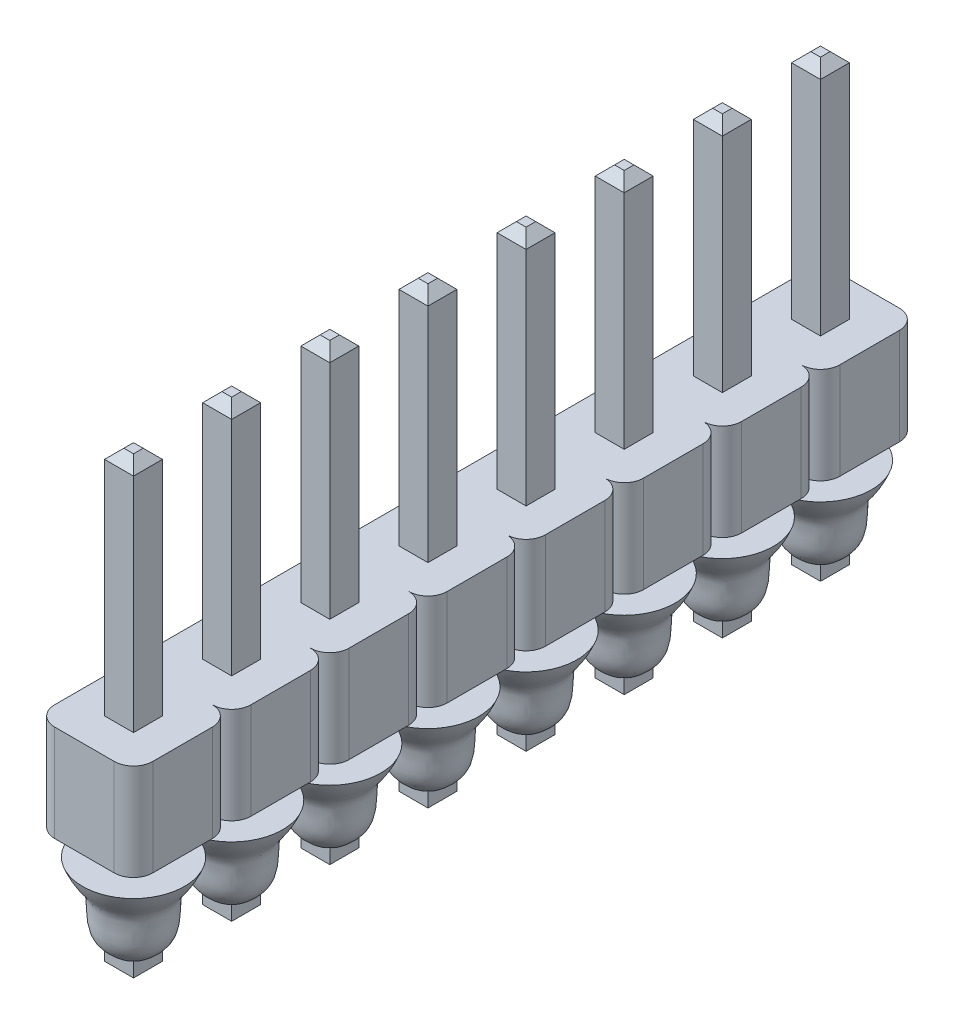
from build123d import *

# Parameters (mm, degrees)
BOSS_EXTRUDE1_DEPTH        = 2.5
LPATTERN1_COUNT            = 8
LPATTERN1_PITCH            = 2.54
BOSS_EXTRUDE2_START        = -3.25
SKETCH2_W                  = 0.75
SKETCH2_H                  = 0.75
BOSS_EXTRUDE2_DEPTH        = 11.75
CHAMFER1_SIZE              = 0.25
LPATTERN2_COUNT            = 8
LPATTERN2_PITCH            = 2.54
CHAMFER1_OF_LPATTERN2_SIZE = 0.25
PADR_O_LINEAR1_COUNT       = 8
PADR_O_LINEAR1_PITCH       = 2.54


with BuildPart() as part:
    # Sketch1 → Boss-Extrude1 (new body)
    with BuildSketch(Plane(origin=(0, 0, 0), x_dir=(-1, 0, 0), z_dir=(0, 1, 0))):
        with BuildLine():
            Line((-0.77, 1.27), (0.77, 1.27))
            ThreePointArc((0.77, 1.27), (1.123553391, 1.123553391), (1.27, 0.77))
            Line((1.27, 0.77), (1.27, -0.77))
            ThreePointArc((1.27, -0.77), (1.123553391, -1.123553391), (0.77, -1.27))
            Line((0.77, -1.27), (-0.77, -1.27))
            ThreePointArc((-0.77, -1.27), (-1.123553391, -1.123553391), (-1.27, -0.77))
            Line((-1.27, -0.77), (-1.27, 0.77))
            ThreePointArc((-1.27, 0.77), (-1.123553391, 1.123553391), (-0.77, 1.27))
        make_face()
    boss_extrude1 = extrude(amount=BOSS_EXTRUDE1_DEPTH)

    # LPattern1: Boss-Extrude1 ×8
    with Locations(*[(0, 0, i * LPATTERN1_PITCH) for i in range(1, LPATTERN1_COUNT)]):
        add(boss_extrude1)

    # Sketch2 → Boss-Extrude2 (add)
    with BuildSketch(Plane(origin=(0, 0, 0), x_dir=(-1, 0, 0), z_dir=(0, 1, 0)).offset(BOSS_EXTRUDE2_START)):
        Rectangle(SKETCH2_W, SKETCH2_H)
    boss_extrude2 = extrude(amount=BOSS_EXTRUDE2_DEPTH)

    # Chamfer1
    chamfer1_edges = [part.edges().sort_by_distance(p)[0] for p in [
        (0, -3.25, 0.375),
        (-0.375, -3.25, 0),
        (0.375, -3.25, 0),
        (0, -3.25, -0.375),
        (0, 8.5, 0.375),
        (-0.375, 8.5, 0),
        (0, 8.5, -0.375),
        (0.375, 8.5, 0),
    ]]
    chamfer(chamfer1_edges, length=CHAMFER1_SIZE)

    # LPattern2: Boss-Extrude2 ×8
    with Locations(*[(0, 0, i * LPATTERN2_PITCH) for i in range(1, LPATTERN2_COUNT)]):
        add(boss_extrude2)

    # Chamfer1 of LPattern2
    chamfer1_of_lpattern2_edges = [part.edges().sort_by_distance(p)[0] for p in [
        (0, -3.25, 2.915),
        (-0.375, -3.25, 2.54),
        (0.375, -3.25, 2.54),
        (0, -3.25, 2.165),
        (0, 8.5, 2.915),
        (-0.375, 8.5, 2.54),
        (0, 8.5, 2.165),
        (0.375, 8.5, 2.54),
        (0, -3.25, 5.455),
        (-0.375, -3.25, 5.08),
        (0.375, -3.25, 5.08),
        (0, -3.25, 4.705),
        (0, 8.5, 5.455),
        (-0.375, 8.5, 5.08),
        (0, 8.5, 4.705),
        (0.375, 8.5, 5.08),
        (0, -3.25, 7.995),
        (-0.375, -3.25, 7.62),
        (0.375, -3.25, 7.62),
        (0, -3.25, 7.245),
        (0, 8.5, 7.995),
        (-0.375, 8.5, 7.62),
        (0, 8.5, 7.245),
        (0.375, 8.5, 7.62),
        (0, -3.25, 10.535),
        (-0.375, -3.25, 10.16),
        (0.375, -3.25, 10.16),
        (0, -3.25, 9.785),
        (0, 8.5, 10.535),
        (-0.375, 8.5, 10.16),
        (0, 8.5, 9.785),
        (0.375, 8.5, 10.16),
        (0, -3.25, 13.075),
        (-0.375, -3.25, 12.7),
        (0.375, -3.25, 12.7),
        (0, -3.25, 12.325),
        (0, 8.5, 13.075),
        (-0.375, 8.5, 12.7),
        (0, 8.5, 12.325),
        (0.375, 8.5, 12.7),
        (0, -3.25, 15.615),
        (-0.375, -3.25, 15.24),
        (0.375, -3.25, 15.24),
        (0, -3.25, 14.865),
        (0, 8.5, 15.615),
        (-0.375, 8.5, 15.24),
        (0, 8.5, 14.865),
        (0.375, 8.5, 15.24),
        (0, -3.25, 18.155),
        (-0.375, -3.25, 17.78),
        (0.375, -3.25, 17.78),
        (0, -3.25, 17.405),
        (0, 8.5, 18.155),
        (-0.375, 8.5, 17.78),
        (0, 8.5, 17.405),
        (0.375, 8.5, 17.78),
    ]]
    chamfer(chamfer1_of_lpattern2_edges, length=CHAMFER1_OF_LPATTERN2_SIZE)

    # Esboço1 → Revolução2 (revolve)
    with BuildSketch(Plane(origin=(0, 0, 0), x_dir=(-1, 0, 0), z_dir=(0, 0, -1))):
        with BuildLine():
            Line((-1.320204823, -0.661301399), (0, -0.661301399))
            Line((0, -0.661301399), (0, -2.979829628))
            add(Edge.make_bspline(
                [(0, -2.979829628), (-0.667262698, -2.583578616), (-0.826136748, -2.272624234), (-0.856036013, -2.003285061), (-0.876854679, -1.189099082), (-1.10334496, -1.219103696), (-1.320204823, -0.661301399)],
                knots=[0, 0, 0, 0, 0.387503858, 0.628702623, 0.689952237, 1, 1, 1, 1], degree=3))
        make_face()
    revolu_o2 = revolve(axis=Axis((0, -3.204155831, 0), (0, 1, 0)))

    # Padrão linear1: Revolução2 ×8
    with Locations(*[(0, 0, i * PADR_O_LINEAR1_PITCH) for i in range(1, PADR_O_LINEAR1_COUNT)]):
        add(revolu_o2)


solid = part.part
